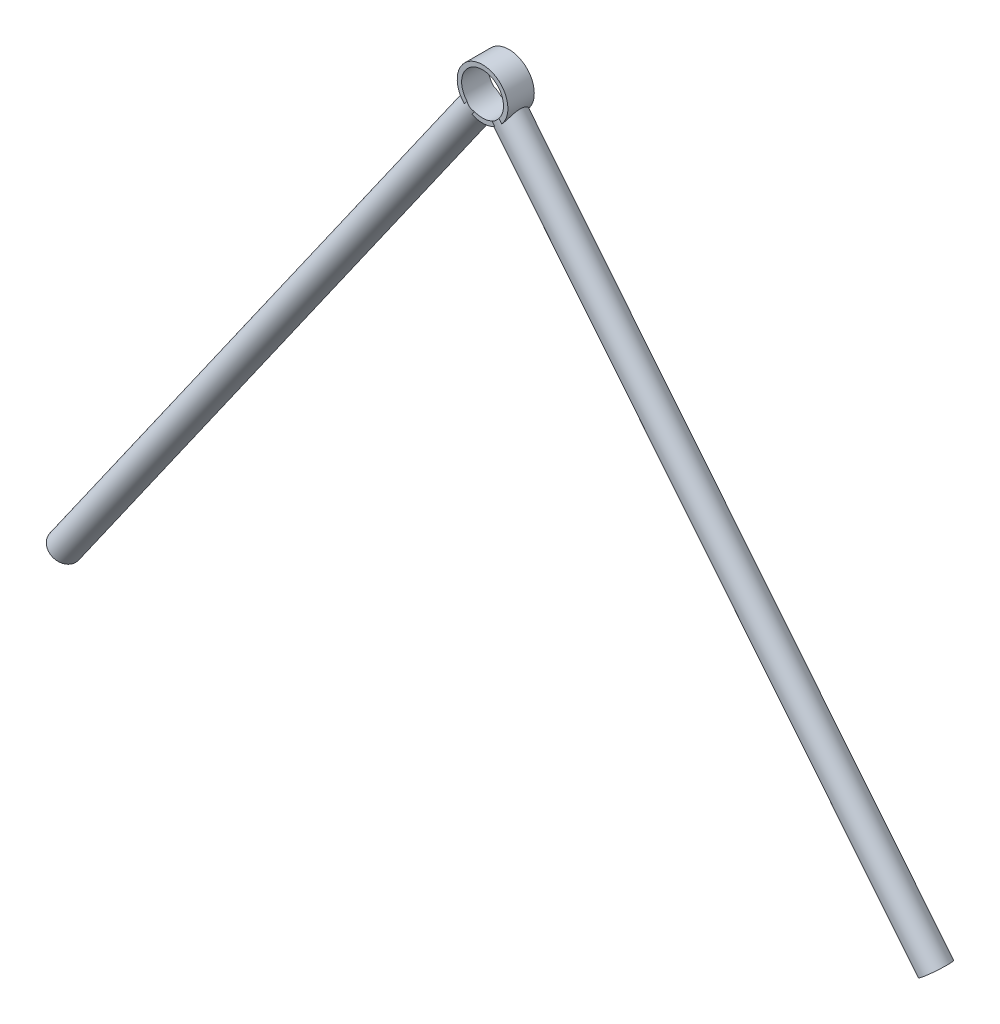
from build123d import *

# Parameters (mm, degrees)
SKETCH1_R               = 11.525000000000015
SKETCH1_R_2             = 9.525000000000018
BOSS_EXTRUDE1_DEPTH     = 6
SWEEP_THIN1_PROFILE_R   = 6.35
SWEEP_THIN1_PROFILE_R_2 = 5.35
SWEEP_THIN2_PROFILE_R   = 6.35
SWEEP_THIN2_PROFILE_R_2 = 5.35
CUT_EXTRUDE1_DEPTH      = 1082.2529065107865
CUT_EXTRUDE1_DEPTH_BACK = 1082.2529065107865
SKETCH1_2_R             = 9.525000000000018


with BuildPart() as part:
    # Sketch1 → Boss-Extrude1 (new, symmetric)
    with BuildSketch(Plane.XY.offset(5.000000000000004)):
        with Locations((709.53, 565.0000000000001)):
            Circle(SKETCH1_R)
        with Locations((709.53, 565.0000000000001)):
            Circle(SKETCH1_R_2, mode=Mode.SUBTRACT)
    extrude(amount=BOSS_EXTRUDE1_DEPTH, both=True)

    # Sweep-Thin1: sweep along a curve in space
    with BuildLine() as sweep_thin1_path:
        Line((709.53, 565.0000000000001, 5.000000000000004), (513.3247676489159, 285.6167716815203, 5.000000000000001))
    # Sweep-Thin1 profile (on start of the path) → Sweep-Thin1 (sweep)
    with BuildSketch(Plane(origin=(709.53, 565.0000000000001, 5.000000000000004), x_dir=(-0.8183544198094448, 0.5747138797509131, 0), z_dir=(-0.5747138797509131, -0.8183544198094448, 0))):
        Circle(SWEEP_THIN1_PROFILE_R)
        Circle(SWEEP_THIN1_PROFILE_R_2, mode=Mode.SUBTRACT)
    sweep(path=sweep_thin1_path.line)

    # Sweep-Thin2: sweep along a curve in space
    with BuildLine() as sweep_thin2_path:
        Line((709.53, 565.0000000000001, 5.000000000000004), (909.7681415974179, 317.39152598279213, 4.999999999999958))
    # Sweep-Thin2 profile (on start of the path) → Sweep-Thin2 (sweep)
    with BuildSketch(Plane(origin=(709.53, 565.0000000000001, 5.000000000000004), x_dir=(-0.7775623816357742, -0.6288058067996055, 0), z_dir=(0.6288058067996055, -0.7775623816357742, 0))):
        Circle(SWEEP_THIN2_PROFILE_R)
        Circle(SWEEP_THIN2_PROFILE_R_2, mode=Mode.SUBTRACT)
    sweep(path=sweep_thin2_path.line)

    # Sketch1_2 → Cut-Extrude1 (cut, two sides: drawn at the far end of the back side and taken through both)
    with BuildSketch(Plane.XY.offset(5.000000000000004).offset(-CUT_EXTRUDE1_DEPTH_BACK)):
        with Locations((709.53, 565.0000000000001)):
            Circle(SKETCH1_2_R)
    extrude(amount=CUT_EXTRUDE1_DEPTH + CUT_EXTRUDE1_DEPTH_BACK, mode=Mode.SUBTRACT)


solid = part.part
